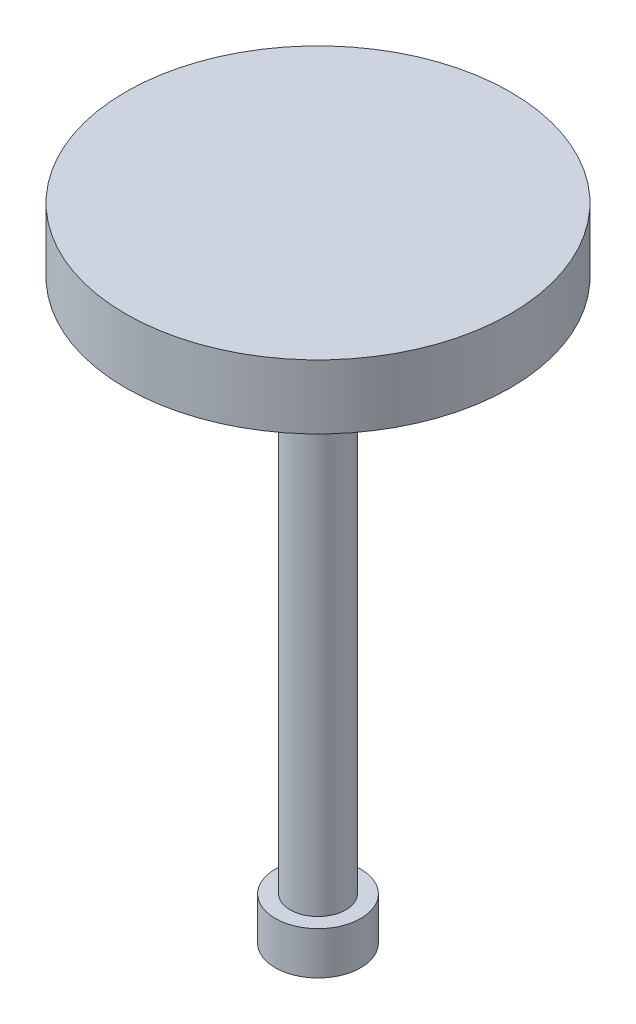
from build123d import *


with BuildPart() as part:
    # Sketch1 → Revolve1 (revolve)
    with BuildSketch(Plane(origin=(0, 0, 0), x_dir=(-1, 0, 0), z_dir=(0, 0, -1))):
        Polygon((-2, -27), (0, -27), (0, 3), (-9, 3), (-9, 0), (-1.305, 0), (-1.305, -25), (-2, -25), align=None)
    revolve(axis=Axis((0, -27, 0), (0, 1, 0)))


solid = part.part
